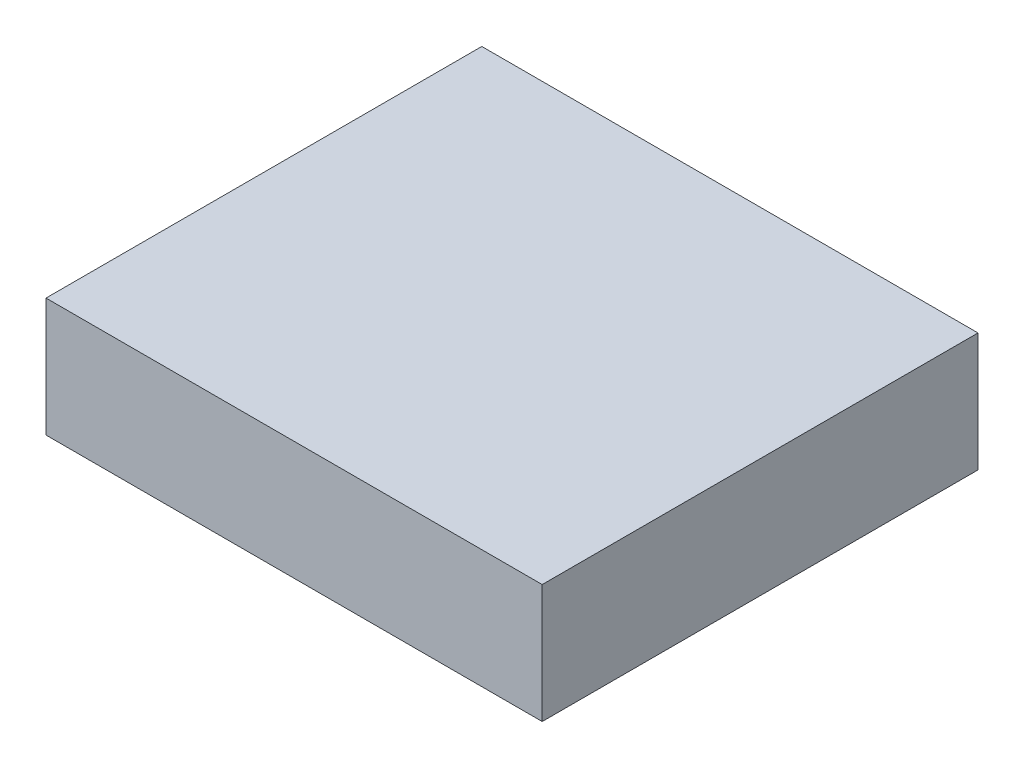
from build123d import *

# Parameters (mm, degrees)
SKETCH1_W           = 115
SKETCH1_H           = 101
BOSS_EXTRUDE1_DEPTH = 27.5


with BuildPart() as part:
    # Sketch1 → Boss-Extrude1 (new body)
    with BuildSketch(Plane(origin=(0, 0, 0), x_dir=(1, 0, 0), z_dir=(0, 1, 0))):
        Rectangle(SKETCH1_W, SKETCH1_H)
    extrude(amount=BOSS_EXTRUDE1_DEPTH)


solid = part.part
